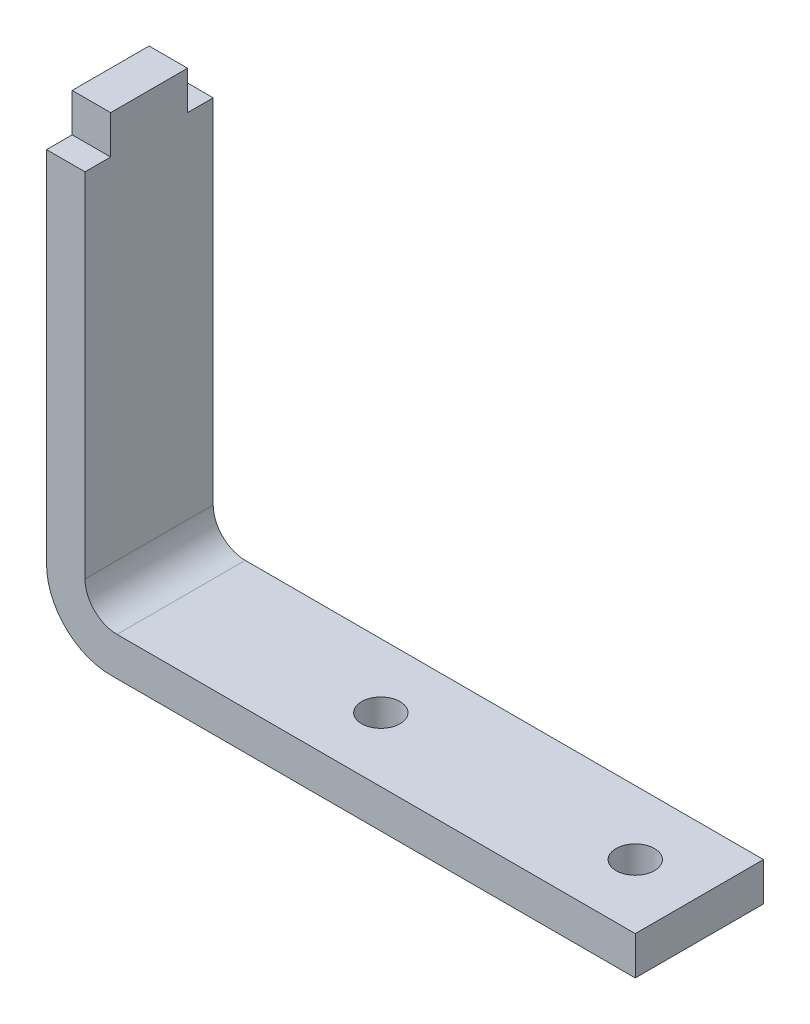
from build123d import *

# Parameters (mm, degrees)
BOSS_EXTRUDE2_DEPTH = 5
SKETCH8_R           = 1.5
CUT_EXTRUDE3_DEPTH  = 3
FILLET7_R           = 5
FILLET8_R           = 2.5
SKETCH9_W           = 13.075
SKETCH9_H           = 10
CUT_EXTRUDE4_DEPTH  = 3
SKETCH11_W          = 3
SKETCH11_H          = 6
BOSS_EXTRUDE4_DEPTH = 3


with BuildPart() as part:
    # Sketch5 → Boss-Extrude2 (new body, symmetric)
    with BuildSketch(Plane.XY):
        Polygon((0, 3), (0, 0), (-59, 0), (-59, 33), (-56, 33), (-56, 3), align=None)
    extrude(amount=BOSS_EXTRUDE2_DEPTH, both=True)

    # Sketch8 → Cut-Extrude3 (cut)
    with BuildSketch(Plane(origin=(0, 3, 0), x_dir=(1, 0, 0), z_dir=(0, 1, 0))):
        with Locations((-18.075, 0)):
            Circle(SKETCH8_R)
        with Locations((-37.925, 0)):
            Circle(SKETCH8_R)
    extrude(amount=-CUT_EXTRUDE3_DEPTH, mode=Mode.SUBTRACT)

    # Fillet7
    fillet7_edges = [part.edges().sort_by_distance(p)[0] for p in [
        (-59, 0, 0),
    ]]
    fillet(fillet7_edges, radius=FILLET7_R)

    # Fillet8
    fillet8_edges = [part.edges().sort_by_distance(p)[0] for p in [
        (-56, 3, 0),
    ]]
    fillet(fillet8_edges, radius=FILLET8_R)

    # Sketch9 → Cut-Extrude4 (cut)
    with BuildSketch(Plane(origin=(0, 3, 0), x_dir=(1, 0, 0), z_dir=(0, 1, 0))):
        with Locations((-6.5375, 0)):
            Rectangle(SKETCH9_W, SKETCH9_H)
    extrude(amount=-CUT_EXTRUDE4_DEPTH, mode=Mode.SUBTRACT)

    # Sketch11 → Boss-Extrude4 (add)
    with BuildSketch(Plane(origin=(0, 33, 0), x_dir=(1, 0, 0), z_dir=(0, 1, 0))):
        with Locations((-57.5, 0)):
            Rectangle(SKETCH11_W, SKETCH11_H)
    extrude(amount=BOSS_EXTRUDE4_DEPTH)


solid = part.part
